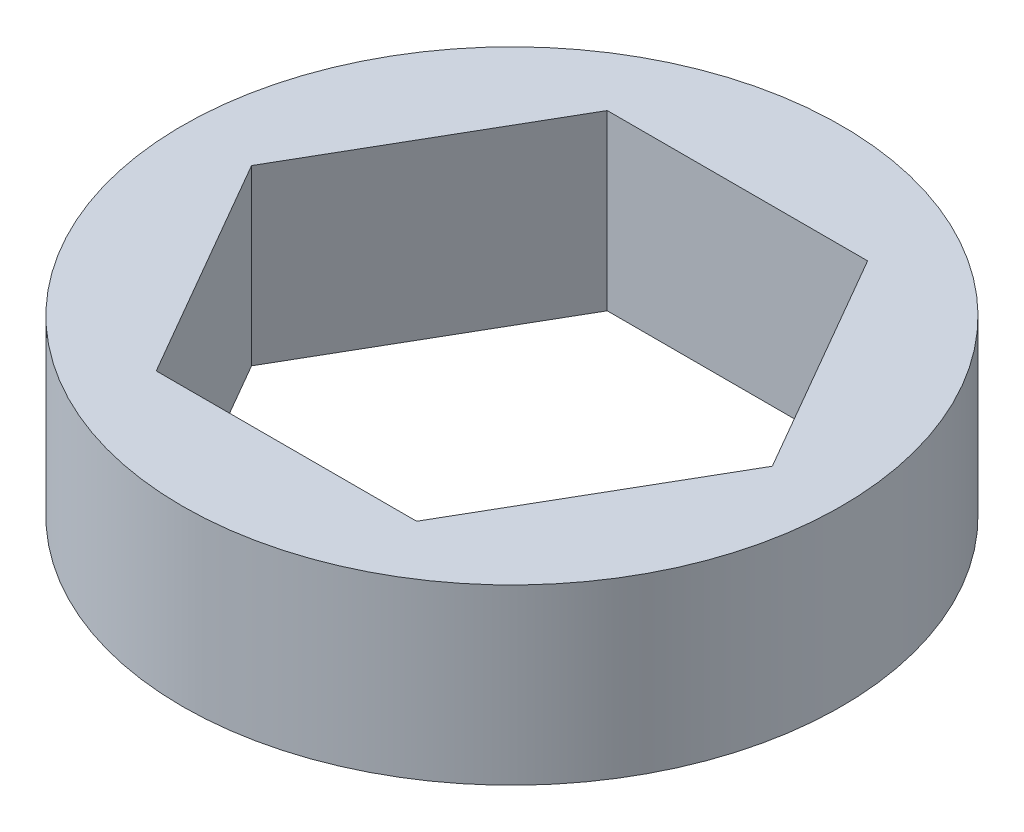
from build123d import *

# Parameters (mm, degrees)
SKETCH1_R           = 9.5
BOSS_EXTRUDE1_DEPTH = 5


with BuildPart() as part:
    # Sketch1 → Boss-Extrude1 (new body)
    with BuildSketch(Plane(origin=(0, 0, 0), x_dir=(1, 0, 0), z_dir=(0, 1, 0))):
        Circle(SKETCH1_R)
        Polygon((7.505553499, 0), (3.75277675, 6.5), (-3.75277675, 6.5), (-7.505553499, 0), (-3.75277675, -6.5), (3.75277675, -6.5), align=None, mode=Mode.SUBTRACT)
    extrude(amount=BOSS_EXTRUDE1_DEPTH)


solid = part.part
